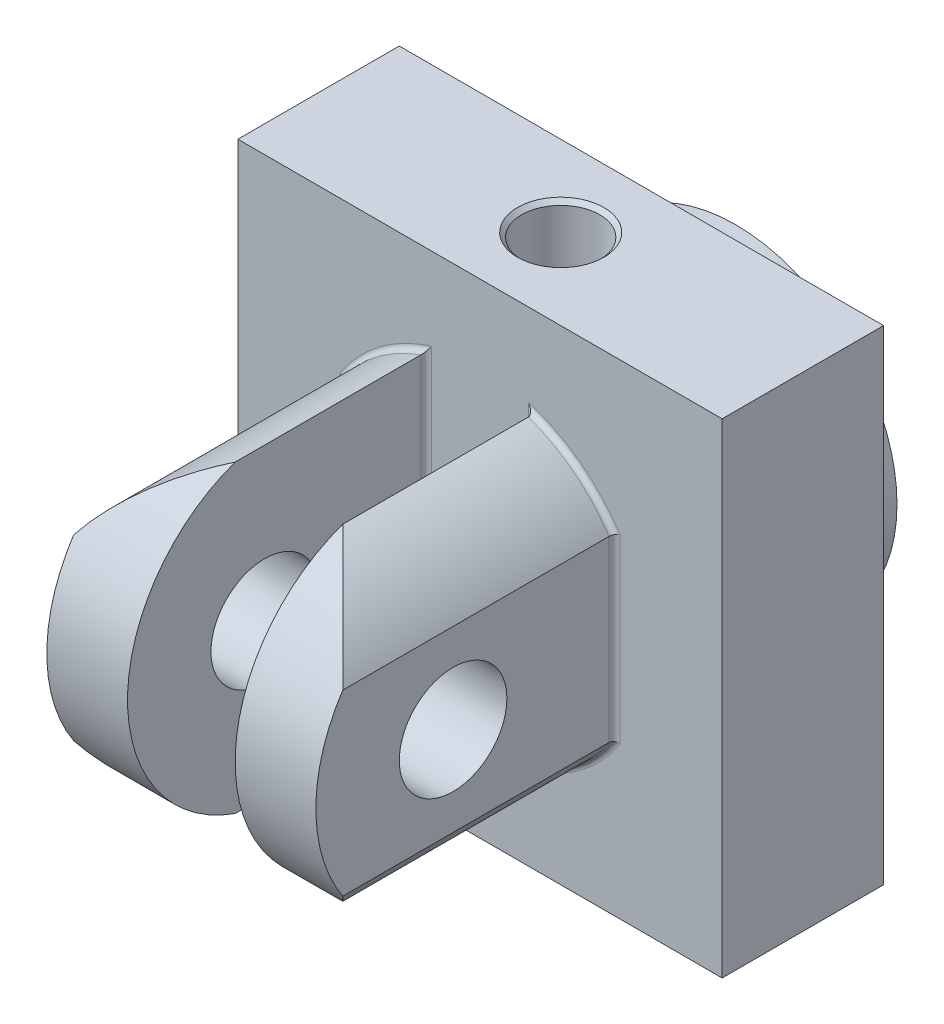
from build123d import *

# Parameters (mm, degrees)
SKETCH2_W                        = 90
SKETCH2_H                        = 90
BOSS_EXTRUDE1_DEPTH              = 103
CUT_EXTRUDE1_DEPTH               = 122.074357318
CUT_EXTRUDE1_DEPTH_BACK          = 122.074357318
SKETCH5_R                        = 10
SKETCH6_W                        = 87.169413833
SKETCH6_H                        = 43.101198191
CUT_EXTRUDE2_DEPTH               = 122.074357403
CUT_EXTRUDE2_DEPTH_BACK          = 122.074357403
CUT_EXTRUDE3_START               = 103
CUT_EXTRUDE3_DEPTH               = 103
CUT_EXTRUDE4_REACH               = 145.993
SKETCH10_R                       = 1.7
FILLET1_R                        = 1
M16X1_5_TAPPED_HOLE2_D           = 14.5
M16X1_5_TAPPED_HOLE2_DEPTH       = 20
M16X1_5_TAPPED_HOLE2_CSINK_D     = 16.05
M16X1_5_TAPPED_HOLE2_CSINK_ANGLE = 90
M16X1_5_TAPPED_HOLE2_TIP         = 4.356239488
CIRPATTERN2_COUNT                = 4


with BuildPart() as part:
    # Sketch2 → Boss-Extrude1 (new body)
    with BuildSketch(Plane.XY):
        Rectangle(SKETCH2_W, SKETCH2_H)
    extrude(amount=BOSS_EXTRUDE1_DEPTH)

    # Sketch4 → Cut-Revolve2 (revolve, cut)
    with BuildSketch(Plane(origin=(0, 0, 0), x_dir=(1, 0, 0), z_dir=(0, 1, 0))):
        Polygon((70, 0), (30, 0), (30, -2.5), (27, -2.5), (27, -6.5), (30, -6.5), (30, -17.5), (70, -17.5), align=None)
        Polygon((24, 0), (0, 0), (0, -39.420654857), (24, -25), align=None)
    revolve(axis=Axis((0, 0, 0), (0, 0, 1)), mode=Mode.SUBTRACT)

    # Sketch5 → Cut-Extrude1 (cut, two sides: drawn at the far end of the back side and taken through both)
    with BuildSketch(Plane(origin=(0, 0, 0), x_dir=(0, 0, -1), z_dir=(1, 0, 0)).offset(-CUT_EXTRUDE1_DEPTH_BACK)):
        with Locations((-77.5, 0)):
            Circle(SKETCH5_R)
    extrude(amount=CUT_EXTRUDE1_DEPTH + CUT_EXTRUDE1_DEPTH_BACK, mode=Mode.SUBTRACT)

    # Sketch6 → Cut-Revolve3 (revolve, cut)
    with BuildSketch(Plane(origin=(0, 0, 0), x_dir=(0, 0, -1), z_dir=(1, 0, 0))):
        with Locations((-91.084706917, 51.550599096)):
            Rectangle(SKETCH6_W, SKETCH6_H)
    revolve(axis=Axis((0, 0, 0), (0, 0, 1)), mode=Mode.SUBTRACT)

    # Sketch7 → Cut-Extrude2 (cut, two sides: drawn at the far end of the back side and taken through both)
    with BuildSketch(Plane(origin=(0, 0, 0), x_dir=(0, 0, -1), z_dir=(1, 0, 0)).offset(-CUT_EXTRUDE2_DEPTH_BACK)):
        with BuildLine():
            ThreePointArc((-77.5, -29.6605799), (-95.748626332, -19.557607216), (-103, 0))
            Line((-103, 0), (-103, -30))
            Line((-103, -30), (-77.5, -30))
            Line((-77.5, -30), (-77.5, -29.6605799))
        make_face()
        with BuildLine():
            Line((-103, 30), (-103, 0))
            ThreePointArc((-103, 0), (-95.748626332, 19.557607216), (-77.5, 29.6605799))
            Line((-77.5, 29.6605799), (-77.5, 30))
            Line((-77.5, 30), (-103, 30))
        make_face()
    extrude(amount=CUT_EXTRUDE2_DEPTH + CUT_EXTRUDE2_DEPTH_BACK, mode=Mode.SUBTRACT)

    # Sketch8 → Cut-Extrude3 (cut)
    with BuildSketch(Plane.XY.offset(47.5).offset(CUT_EXTRUDE3_START)):
        with BuildLine():
            ThreePointArc((10, 28.284271247), (0, 30), (-10, 28.284271247))
            Line((-10, 28.284271247), (-10, -28.284271247))
            ThreePointArc((-10, -28.284271247), (0, -30), (10, -28.284271247))
            Line((10, -28.284271247), (10, 28.284271247))
        make_face()
        with BuildLine():
            Line((-25, -16.583123952), (-25, 16.583123952))
            ThreePointArc((-25, 16.583123952), (-30, 0), (-25, -16.583123952))
        make_face()
        with BuildLine():
            ThreePointArc((25, -16.583123952), (30, 0), (25, 16.583123952))
            Line((25, 16.583123952), (25, -16.583123952))
        make_face()
    extrude(amount=-CUT_EXTRUDE3_DEPTH, mode=Mode.SUBTRACT)

    # Sketch10 → Cut-Extrude4 (cut, up to next)
    with BuildSketch(Plane(origin=(0, 45, 0), x_dir=(1, 0, 0), z_dir=(0, 1, 0)), mode=Mode.PRIVATE) as cut_extrude4_sk1:
        with Locations((0, -32.5)):
            Circle(SKETCH10_R)
    cut_extrude4_tool1 = extrude(cut_extrude4_sk1.sketch, amount=-CUT_EXTRUDE4_REACH, mode=Mode.PRIVATE) & part.part
    add(cut_extrude4_tool1.solids().sort_by_distance((0, 45, 32.5))[0], mode=Mode.SUBTRACT)

    # Fillet1
    fillet1_edges = [part.edges().sort_by_distance(p)[0] for p in [
        (-10, 0, 47.5),
        (-18.452078799, 23.654191764, 47.5),
        (-25, 0, 47.5),
        (-18.452078799, -23.654191764, 47.5),
        (10, 0, 47.5),
        (18.452078799, -23.654191764, 47.5),
        (25, 0, 47.5),
        (18.452078799, 23.654191764, 47.5),
        (-30, 0, 17.5),
    ]]
    fillet(fillet1_edges, radius=FILLET1_R)

    # M16x1.5 Tapped Hole2
    with Locations(Plane(origin=(0, 45, 0), x_dir=(1, 0, 0), z_dir=(0, 1, 0))):
        with Locations((0, -32.5)):
            CounterSinkHole(M16X1_5_TAPPED_HOLE2_D / 2, M16X1_5_TAPPED_HOLE2_CSINK_D / 2, depth=M16X1_5_TAPPED_HOLE2_DEPTH, counter_sink_angle=M16X1_5_TAPPED_HOLE2_CSINK_ANGLE)
            with Locations((0, 0, -(M16X1_5_TAPPED_HOLE2_DEPTH + M16X1_5_TAPPED_HOLE2_TIP / 2))):  # 118° drill point
                Cone(0, M16X1_5_TAPPED_HOLE2_D / 2, M16X1_5_TAPPED_HOLE2_TIP, mode=Mode.SUBTRACT)

    # Sketch25 → M12x1.5 Tapped Hole1 (revolve, cut)
    with BuildSketch(Plane(origin=(31.819805153, 31.819805153, 17.5), x_dir=(0, 1, 0), z_dir=(1, 0, 0))):
        Polygon((0, 0), (0, 23.15451825), (5.25, 20), (5.25, 0.775), (6.025, 0), align=None)
    m12x1_5_tapped_hole1 = revolve(axis=Axis((31.819805153, 31.819805153, 11.15), (0, 0, 1)), mode=Mode.SUBTRACT)

    # CirPattern2: M12x1.5 Tapped Hole1 ×4 about axis
    cirpattern2_axis = Axis((0, 0, 0), (0, 0, 1))
    for i in range(1, CIRPATTERN2_COUNT):
        add(m12x1_5_tapped_hole1.rotate(cirpattern2_axis, i * 360 / CIRPATTERN2_COUNT), mode=Mode.SUBTRACT)


solid = part.part
